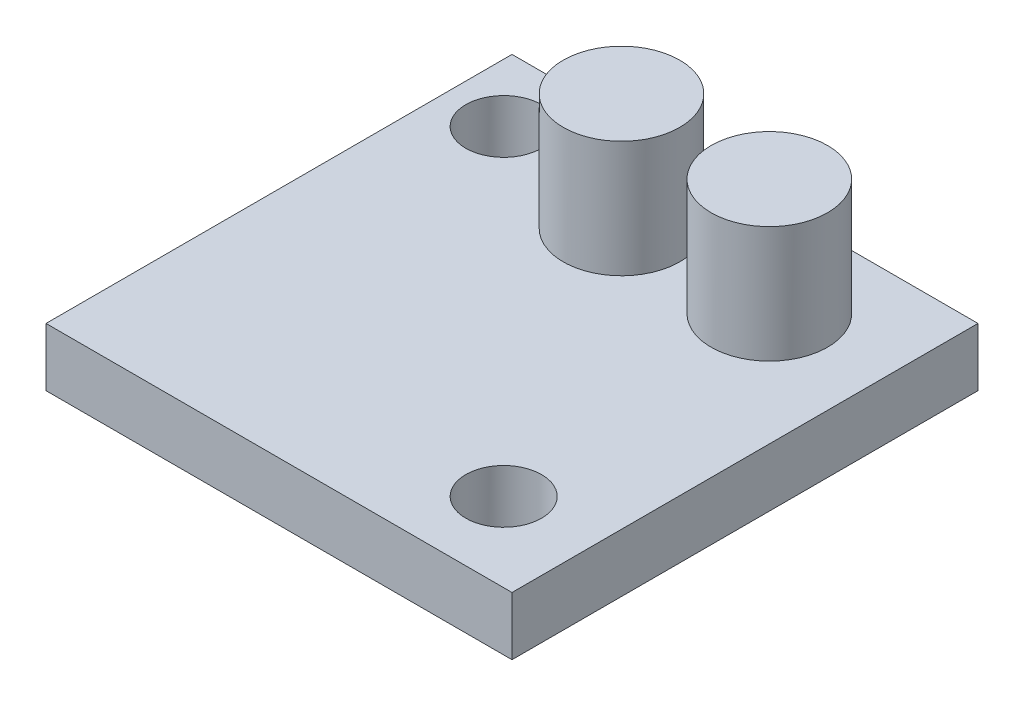
from build123d import *

# Parameters (mm, degrees)
SKETCH1_W           = 20.32
SKETCH1_H           = 20.32
BOSS_EXTRUDE1_DEPTH = 2.54
CUT_EXTRUDE1_REACH  = 4.54
SKETCH2_R           = 1.651
SKETCH3_R           = 2.54
BOSS_EXTRUDE2_DEPTH = 5.08


with BuildPart() as part:
    # Sketch1 → Boss-Extrude1 (new body)
    with BuildSketch(Plane(origin=(0, 0, 0), x_dir=(1, 0, 0), z_dir=(0, 1, 0))):
        with Locations((10.16, 10.16)):
            Rectangle(SKETCH1_W, SKETCH1_H)
    extrude(amount=BOSS_EXTRUDE1_DEPTH)

    # Sketch2 → Cut-Extrude1 (cut, up to next)
    with BuildSketch(Plane(origin=(0, 2.54, 0), x_dir=(1, 0, 0), z_dir=(0, 1, 0)), mode=Mode.PRIVATE) as cut_extrude1_sk1:
        with Locations((2.54, 17.416590364)):
            Circle(SKETCH2_R)
    cut_extrude1_tool1 = extrude(cut_extrude1_sk1.sketch, amount=-CUT_EXTRUDE1_REACH, mode=Mode.PRIVATE) & part.part
    add(cut_extrude1_tool1.solids().sort_by_distance((2.54, 2.54, -17.41659))[0], mode=Mode.SUBTRACT)
    # Sketch2 → Cut-Extrude1 (cut, up to next)
    with BuildSketch(Plane(origin=(0, 2.54, 0), x_dir=(1, 0, 0), z_dir=(0, 1, 0)), mode=Mode.PRIVATE) as cut_extrude1_sk2:
        with Locations((16.51, 3.446590364)):
            Circle(SKETCH2_R)
    cut_extrude1_tool2 = extrude(cut_extrude1_sk2.sketch, amount=-CUT_EXTRUDE1_REACH, mode=Mode.PRIVATE) & part.part
    add(cut_extrude1_tool2.solids().sort_by_distance((16.51, 2.54, -3.44659))[0], mode=Mode.SUBTRACT)

    # Sketch3 → Boss-Extrude2 (add)
    with BuildSketch(Plane(origin=(0, 2.54, 0), x_dir=(1, 0, 0), z_dir=(0, 1, 0))):
        with Locations((8.953441032, 16.141085169)):
            Circle(SKETCH3_R)
        with Locations((15.399913232, 16.141085169)):
            Circle(SKETCH3_R)
    extrude(amount=BOSS_EXTRUDE2_DEPTH)


solid = part.part
